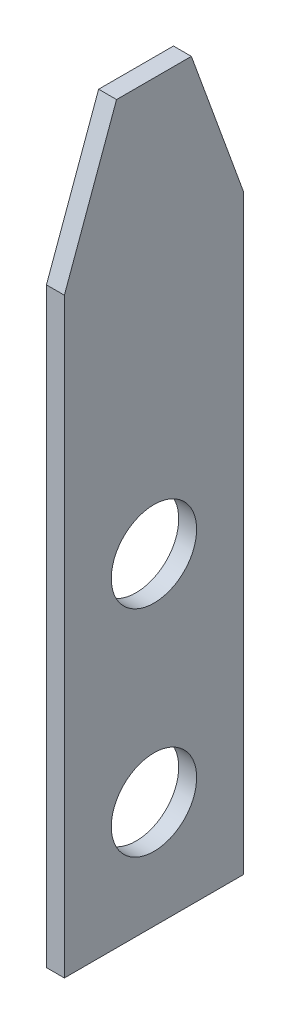
from build123d import *

# Parameters (mm, degrees)
SKETCH_1_W             = 5
SKETCH_1_H             = 20.5
EXTRUDE_1_DEPTH        = 0.5
HOLE_WIZARD_21_D       = 2.38252
CHAMFER_1_SIZE         = 4
CHAMFER_1_SIZE2        = 1.455880937
CHAMFER_1_PART_2_SIZE  = 4
CHAMFER_1_PART_2_SIZE2 = 1.455880937


with BuildPart() as part:
    # Эскиз1 → Бобышка-Вытянуть1 (new body)
    with BuildSketch(Plane(origin=(0, 0, 0), x_dir=(0, 0, -1), z_dir=(1, 0, 0))):
        with Locations((2.5, 10.25)):
            Rectangle(SKETCH_1_W, SKETCH_1_H)
    extrude(amount=EXTRUDE_1_DEPTH)

    # Сверло под метчик  спиральное #21 (through all)
    with Locations(Plane.ZY):
        with Locations((-2.5, 3), (-2.5, 9)):
            Hole(HOLE_WIZARD_21_D / 2)

    # Фаска1
    chamfer_1_edges = [part.edges().sort_by_distance(p)[0] for p in [
        (0.25, 20.5, 0),
    ]]
    chamfer_1_side = [part.faces().sort_by_distance(p)[0] for p in [
        (0.25, 10.25, 0),
    ]]
    chamfer(chamfer_1_edges, length=CHAMFER_1_SIZE, length2=CHAMFER_1_SIZE2, reference=chamfer_1_side[0])

    # Фаска1 part 2
    chamfer_1_part_2_edges = [part.edges().sort_by_distance(p)[0] for p in [
        (0.25, 20.5, -5),
    ]]
    chamfer_1_part_2_side = [part.faces().sort_by_distance(p)[0] for p in [
        (0.25, 10.25, -5),
    ]]
    chamfer(chamfer_1_part_2_edges, length=CHAMFER_1_PART_2_SIZE, length2=CHAMFER_1_PART_2_SIZE2, reference=chamfer_1_part_2_side[0])


solid = part.part
